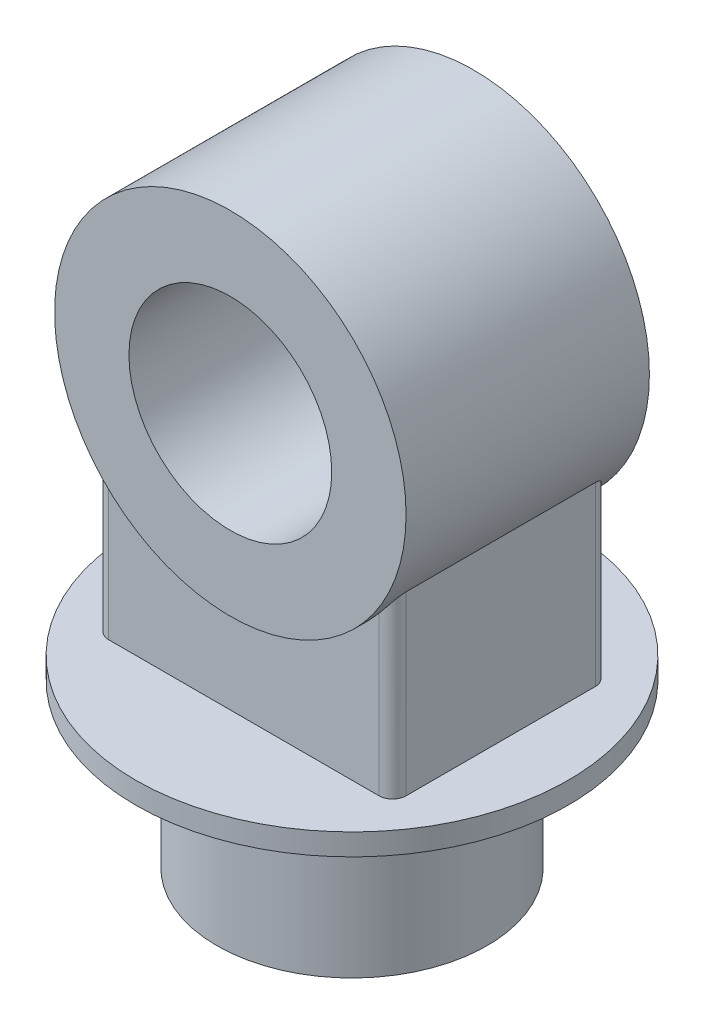
from build123d import *

# Parameters (mm, degrees)
IZIM1_R                          = 100
Y_KSEKLIK_EKSTR_ZYON1_DEPTH      = 120
IZIM2_R                          = 160
Y_KSEKLIK_EKSTR_ZYON2_DEPTH      = 16
IZIM3_R                          = 130
IZIM3_R_2                        = 75
Y_KSEKLIK_EKSTR_ZYON3_DEPTH      = 90
Y_KSEKLIK_EKSTR_ZYON4_REACH      = 402.125
Y_KSEKLIK_EKSTR_ZYON4_END_RADIUS = 130
IZIM5_W                          = 220
IZIM5_H                          = 160
RADYUS1_R                        = 10


with BuildPart() as part:
    # Çizim1 → Yükseklik-Ekstrüzyon1 (new body)
    with BuildSketch(Plane(origin=(0, 0, 0), x_dir=(1, 0, 0), z_dir=(0, 1, 0))):
        with Locations(Location((0, 0, 0), (0, 0, 270))):
            Circle(IZIM1_R)
    extrude(amount=Y_KSEKLIK_EKSTR_ZYON1_DEPTH)

    # Çizim2 → Yükseklik-Ekstrüzyon2 (add)
    with BuildSketch(Plane(origin=(0, 120, 0), x_dir=(1, 0, 0), z_dir=(0, 1, 0))):
        with Locations(Location((0, 0, 0), (0, 0, 270))):
            Circle(IZIM2_R)
    extrude(amount=Y_KSEKLIK_EKSTR_ZYON2_DEPTH)



with BuildPart() as body_2:
    # Çizim3 → Yükseklik-Ekstrüzyon3 (new, symmetric)
    with BuildSketch(Plane.XY):
        with Locations(Location((0, 336, 0), (0, 0, 180))):
            Circle(IZIM3_R)
        with Locations(Location((0, 336, 0), (0, 0, 180))):
            Circle(IZIM3_R_2, mode=Mode.SUBTRACT)
    extrude(amount=Y_KSEKLIK_EKSTR_ZYON3_DEPTH, both=True)


with BuildPart() as part_1:
    add(part.part)

    add(body_2.part)  # Yükseklik-Ekstrüzyon4 merges body 2
    # Yükseklik-Ekstrüzyon4: up to this cylinder (the profile starts outside it)
    y_kseklik_ekstr_zyon4_end = Plane(origin=(0, 336, 0), z_dir=(0, 0, -1)) * Cylinder(Y_KSEKLIK_EKSTR_ZYON4_END_RADIUS, 1065.25, mode=Mode.PRIVATE)
    # Çizim5 → Yükseklik-Ekstrüzyon4 (add, up to the surface)
    with BuildSketch(Plane(origin=(0, 136, 0), x_dir=(1, 0, 0), z_dir=(0, 1, 0)), mode=Mode.PRIVATE) as y_kseklik_ekstr_zyon4_sk1:
        Rectangle(IZIM5_W, IZIM5_H)
    y_kseklik_ekstr_zyon4_tool1 = extrude(y_kseklik_ekstr_zyon4_sk1.sketch, amount=Y_KSEKLIK_EKSTR_ZYON4_REACH, mode=Mode.PRIVATE) - y_kseklik_ekstr_zyon4_end
    add(y_kseklik_ekstr_zyon4_tool1.solids().sort_by_distance((0, 136, 0))[0])

    # Radyus1
    radyus1_edges = [part_1.edges().sort_by_distance(p)[0] for p in [
        (110, 201.358983849, -80),
        (110, 201.358983849, 80),
        (-110, 201.358983849, -80),
        (-110, 201.358983849, 80),
    ]]
    fillet(radyus1_edges, radius=RADYUS1_R)


solid = part_1.part
